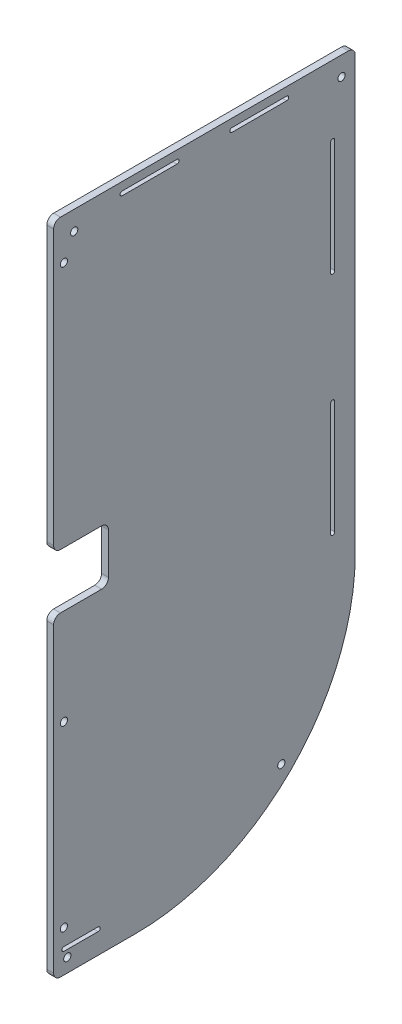
from build123d import *

# Parameters (mm, degrees)
BOSS_EXTRUDE1_DEPTH     = 6.35
SKETCH2_R               = 3.3655
CUT_EXTRUDE1_DEPTH      = 7.35
FILLET1_R               = 6.35
CUT_EXTRUDE6_DEPTH      = 7.35
SKETCH4_R               = 3.3655
CUT_EXTRUDE3_DEPTH      = 7.35
CUT_EXTRUDE7_DEPTH      = 7.35
CUT_EXTRUDE8_DEPTH      = 1
CUT_EXTRUDE8_DEPTH_BACK = 7.35
SKETCH8_W               = 50.8
SKETCH8_H               = 50.8
CUT_EXTRUDE9_DEPTH      = 7.35
FILLET2_R               = 6.35


with BuildPart() as part:
    # Sketch1 → Boss-Extrude1 (new body)
    with BuildSketch(Plane(origin=(0, 0, 0), x_dir=(0, 0, -1), z_dir=(1, 0, 0))):
        with BuildLine():
            Line((0, 0), (0, -609.6))
            Line((0, -609.6), (76.2, -609.6))
            ThreePointArc((76.2, -609.6), (219.884097937, -550.084097937), (279.4, -406.4))
            Line((279.4, -406.4), (279.4, 0))
            Line((279.4, 0), (0, 0))
        make_face()
    extrude(amount=BOSS_EXTRUDE1_DEPTH)

    # Sketch2 → Cut-Extrude1 (cut, through all)
    with BuildSketch(Plane(origin=(6.35, 0, 0), x_dir=(0, 0, -1), z_dir=(1, 0, 0))):
        with Locations((266.7, -17.78)):
            Circle(SKETCH2_R)
        with Locations((12.7, -596.9)):
            Circle(SKETCH2_R)
        with Locations((210.903841816, -541.103841816)):
            Circle(SKETCH2_R)
        with Locations((19.05, -17.78)):
            Circle(SKETCH2_R)
    extrude(amount=-CUT_EXTRUDE1_DEPTH, mode=Mode.SUBTRACT)

    # Fillet1
    fillet1_edges = [part.edges().sort_by_distance(p)[0] for p in [
        (3.175, 0, -279.4),
        (3.175, -609.6, 0),
        (3.175, 0, 0),
    ]]
    fillet(fillet1_edges, radius=FILLET1_R)

    # Sketch3 → Cut-Extrude6 (cut, through all)
    with BuildSketch(Plane(origin=(6.35, 0, 0), x_dir=(0, 0, -1), z_dir=(1, 0, 0))):
        with BuildLine():
            Line((63.5, -7.62), (114.3, -7.62))
            ThreePointArc((114.3, -7.62), (116.205, -9.525), (114.3, -11.43))
            Line((114.3, -11.43), (63.5, -11.43))
            ThreePointArc((63.5, -11.43), (61.595, -9.525), (63.5, -7.62))
        make_face()
        with BuildLine():
            Line((165.1, -7.62), (215.9, -7.62))
            ThreePointArc((215.9, -7.62), (217.805, -9.525), (215.9, -11.43))
            Line((215.9, -11.43), (165.1, -11.43))
            ThreePointArc((165.1, -11.43), (163.195, -9.525), (165.1, -7.62))
        make_face()
    extrude(amount=-CUT_EXTRUDE6_DEPTH, mode=Mode.SUBTRACT)

    # Sketch4 → Cut-Extrude3 (cut, through all)
    with BuildSketch(Plane(origin=(6.35, 0, 0), x_dir=(0, 0, -1), z_dir=(1, 0, 0))):
        with Locations((9.525, -38.1)):
            Circle(SKETCH4_R)
        with Locations((9.525, -406.4)):
            Circle(SKETCH4_R)
        with Locations((9.525, -571.5)):
            Circle(SKETCH4_R)
    extrude(amount=-CUT_EXTRUDE3_DEPTH, mode=Mode.SUBTRACT)

    # Sketch6 → Cut-Extrude7 (cut, through all)
    with BuildSketch(Plane(origin=(6.35, 0, 0), x_dir=(0, 0, -1), z_dir=(1, 0, 0))):
        with BuildLine():
            Line((260.35, -65.0875), (260.35, -169.8625))
            ThreePointArc((260.35, -169.8625), (258.445, -171.7675), (256.54, -169.8625))
            Line((256.54, -169.8625), (256.54, -65.0875))
            ThreePointArc((256.54, -65.0875), (258.445, -63.1825), (260.35, -65.0875))
        make_face()
        with BuildLine():
            Line((256.54, -379.4125), (256.54, -274.6375))
            ThreePointArc((256.54, -274.6375), (258.445, -272.7325), (260.35, -274.6375))
            Line((260.35, -274.6375), (260.35, -379.4125))
            ThreePointArc((260.35, -379.4125), (258.445, -381.3175), (256.54, -379.4125))
        make_face()
    extrude(amount=-CUT_EXTRUDE7_DEPTH, mode=Mode.SUBTRACT)

    # Sketch7 → Cut-Extrude8 (cut, two sides)
    with BuildSketch(Plane(origin=(6.35, 0, 0), x_dir=(0, 0, -1), z_dir=(1, 0, 0))) as cut_extrude8_sk:
        with BuildLine():
            Line((9.525, -586.74), (41.275, -586.74))
            ThreePointArc((41.275, -586.74), (43.18, -588.645), (41.275, -590.55))
            Line((41.275, -590.55), (9.525, -590.55))
            ThreePointArc((9.525, -590.55), (7.62, -588.645), (9.525, -586.74))
        make_face()
    extrude(amount=CUT_EXTRUDE8_DEPTH, mode=Mode.SUBTRACT)
    extrude(cut_extrude8_sk.sketch, amount=-CUT_EXTRUDE8_DEPTH_BACK, mode=Mode.SUBTRACT)

    # Sketch8 → Cut-Extrude9 (cut, through all)
    with BuildSketch(Plane(origin=(6.35, 0, 0), x_dir=(0, 0, -1), z_dir=(1, 0, 0))):
        with Locations((25.4, -292.1)):
            Rectangle(SKETCH8_W, SKETCH8_H)
    extrude(amount=-CUT_EXTRUDE9_DEPTH, mode=Mode.SUBTRACT)

    # Fillet2
    fillet2_edges = [part.edges().sort_by_distance(p)[0] for p in [
        (3.175, -317.5, 0),
        (3.175, -266.7, 0),
        (3.175, -266.7, -50.8),
        (3.175, -317.5, -50.8),
    ]]
    fillet(fillet2_edges, radius=FILLET2_R)


solid = part.part
